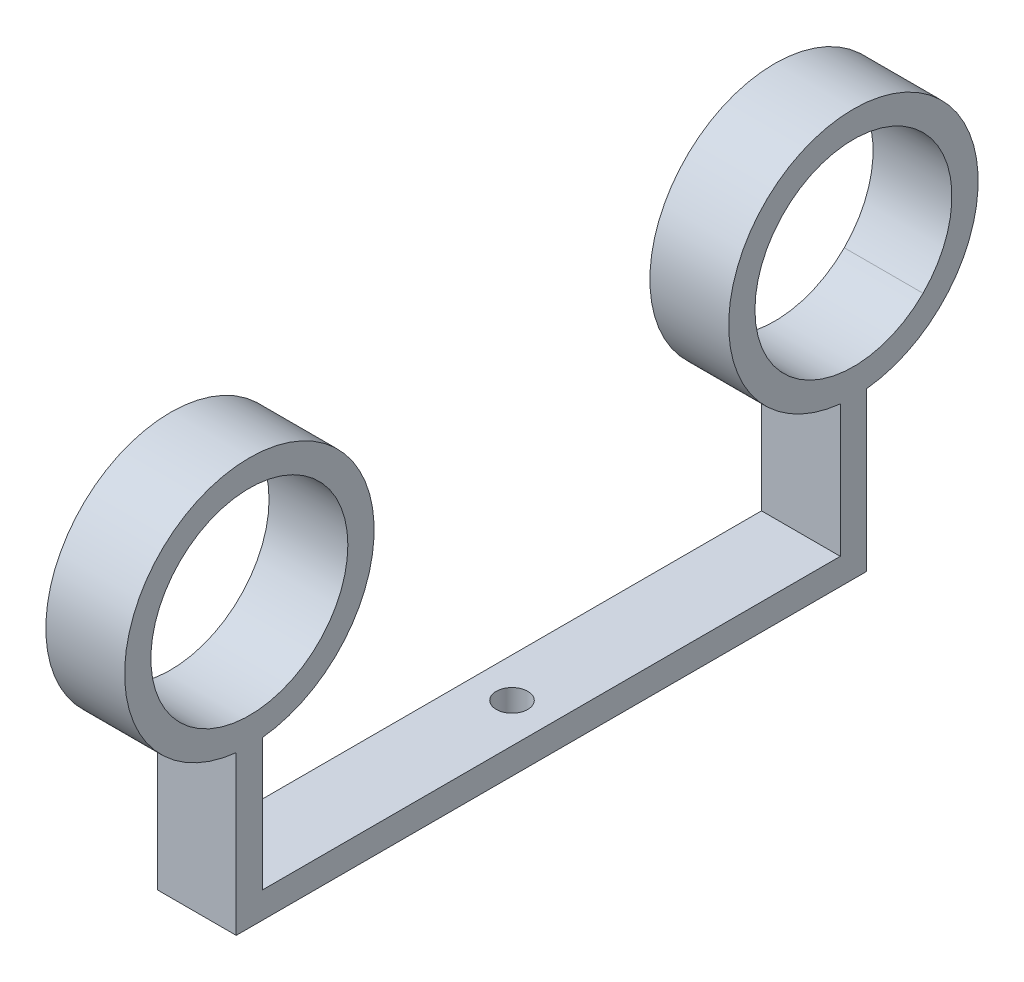
from build123d import *

# Parameters (mm, degrees)
EXTRUDE_THIN2_DEPTH     = 30
SKETCH2_R               = 47.5
SKETCH2_R_2             = 37.5
EXTRUDE_THIN3_DEPTH     = 30
SKETCH3_R               = 6
CUT_EXTRUDE1_DEPTH      = 146
CUT_EXTRUDE1_DEPTH_BACK = 11


with BuildPart() as part:
    # Sketch1 → Extrude-Thin2 (new body)
    with BuildSketch(Plane(origin=(0, 0, 0), x_dir=(0, 0, -1), z_dir=(1, 0, 0))):
        Polygon((0, 0), (120, 0), (120, 70), (110, 70), (110, 10), (0, 10), align=None)
    extrude(amount=EXTRUDE_THIN2_DEPTH)

    # Sketch2 → Extrude-Thin3 (add)
    with BuildSketch(Plane(origin=(30, 0, 0), x_dir=(0, 0, -1), z_dir=(1, 0, 0))):
        with Locations((115, 107.5)):
            Circle(SKETCH2_R)
        with Locations((115, 107.5)):
            Circle(SKETCH2_R_2, mode=Mode.SUBTRACT)
    extrude(amount=-EXTRUDE_THIN3_DEPTH)

    # Mirror1: part across plane


with BuildPart() as part_1:
    add(part.part)
    add(part.part.mirror(Plane(origin=(30, 0, 0), x_dir=(1, 0, 0), z_dir=(0, 0, 1))))

    # Sketch3 → Cut-Extrude1 (cut, two sides)
    with BuildSketch(Plane(origin=(0, 10, 0), x_dir=(1, 0, 0), z_dir=(0, 1, 0))) as cut_extrude1_sk:
        with Locations((15, 0)):
            Circle(SKETCH3_R)
    extrude(amount=CUT_EXTRUDE1_DEPTH, mode=Mode.SUBTRACT)
    extrude(cut_extrude1_sk.sketch, amount=-CUT_EXTRUDE1_DEPTH_BACK, mode=Mode.SUBTRACT)


solid = part_1.part
